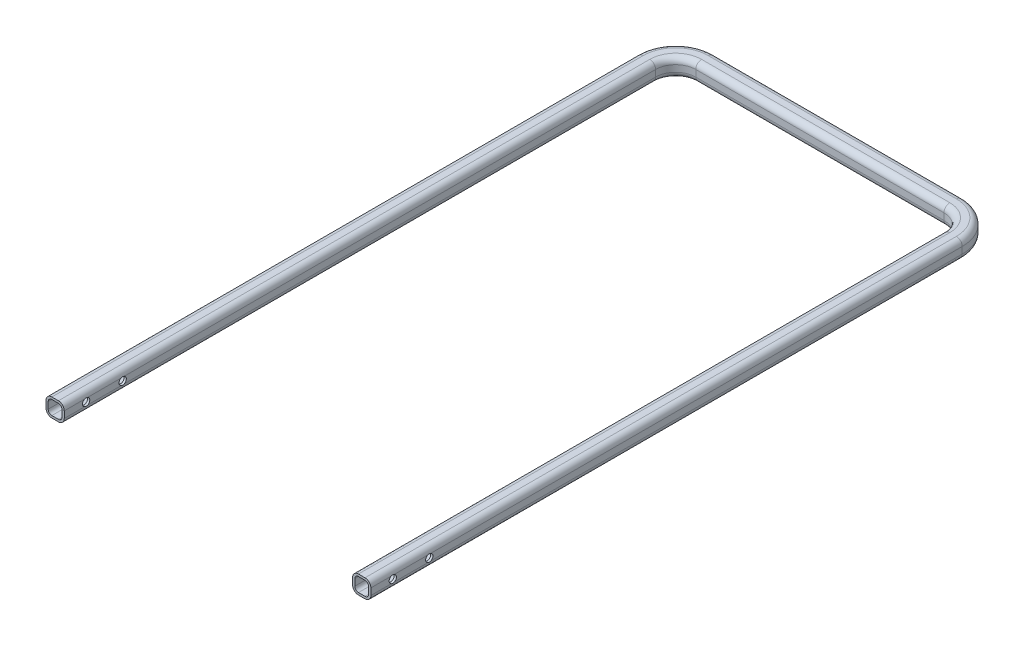
from build123d import *

# Parameters (mm, degrees)
SKETCH4_R               = 5
CUT_EXTRUDE2_DEPTH      = 433.5000001
CUT_EXTRUDE2_DEPTH_BACK = 13.5000001


with BuildPart() as part:
    # Sweep-Thin1: sweep along a path in Sketch1
    with BuildLine(Plane(origin=(0, 0, 0), x_dir=(1, 0, 0), z_dir=(0, 1, 0))) as sweep_thin1_path:
        Line((0, 0), (0, 810))
        ThreePointArc((0, 810), (11.715728753, 838.284271247), (40, 850))
        Line((40, 850), (380, 850))
        ThreePointArc((380, 850), (408.284271247, 838.284271247), (420, 810))
        Line((420, 810), (420, 0))
    # Sketch3 → Sweep-Thin1 (sweep)
    with BuildSketch(Plane.XY):
        with BuildLine():
            Line((4.5, 12.5), (-4.5, 12.5))
            ThreePointArc((-4.5, 12.5), (-10.156854249, 10.156854249), (-12.5, 4.5))
            Line((-12.5, 4.5), (-12.5, -4.5))
            ThreePointArc((-12.5, -4.5), (-10.156854249, -10.156854249), (-4.5, -12.5))
            Line((-4.5, -12.5), (4.5, -12.5))
            ThreePointArc((4.5, -12.5), (10.156854249, -10.156854249), (12.5, -4.5))
            Line((12.5, -4.5), (12.5, 4.5))
            ThreePointArc((12.5, 4.5), (10.156854249, 10.156854249), (4.5, 12.5))
        make_face()
        with BuildLine():
            Line((4.5, 9.5), (-4.5, 9.5))
            ThreePointArc((-4.5, 9.5), (-8.035533906, 8.035533906), (-9.5, 4.5))
            Line((-9.5, 4.5), (-9.5, -4.5))
            ThreePointArc((-9.5, -4.5), (-8.035533906, -8.035533906), (-4.5, -9.5))
            Line((-4.5, -9.5), (4.5, -9.5))
            ThreePointArc((4.5, -9.5), (8.035533906, -8.035533906), (9.5, -4.5))
            Line((9.5, -4.5), (9.5, 4.5))
            ThreePointArc((9.5, 4.5), (8.035533906, 8.035533906), (4.5, 9.5))
        make_face(mode=Mode.SUBTRACT)
    sweep(path=sweep_thin1_path.line)

    # Sketch4 → Cut-Extrude2 (cut, two sides)
    with BuildSketch(Plane(origin=(0, 0, 0), x_dir=(0, 0, -1), z_dir=(1, 0, 0))) as cut_extrude2_sk:
        with Locations((30, 0)):
            Circle(SKETCH4_R)
        with Locations((80, 0)):
            Circle(SKETCH4_R)
    extrude(amount=CUT_EXTRUDE2_DEPTH, mode=Mode.SUBTRACT)
    extrude(cut_extrude2_sk.sketch, amount=-CUT_EXTRUDE2_DEPTH_BACK, mode=Mode.SUBTRACT)


solid = part.part
